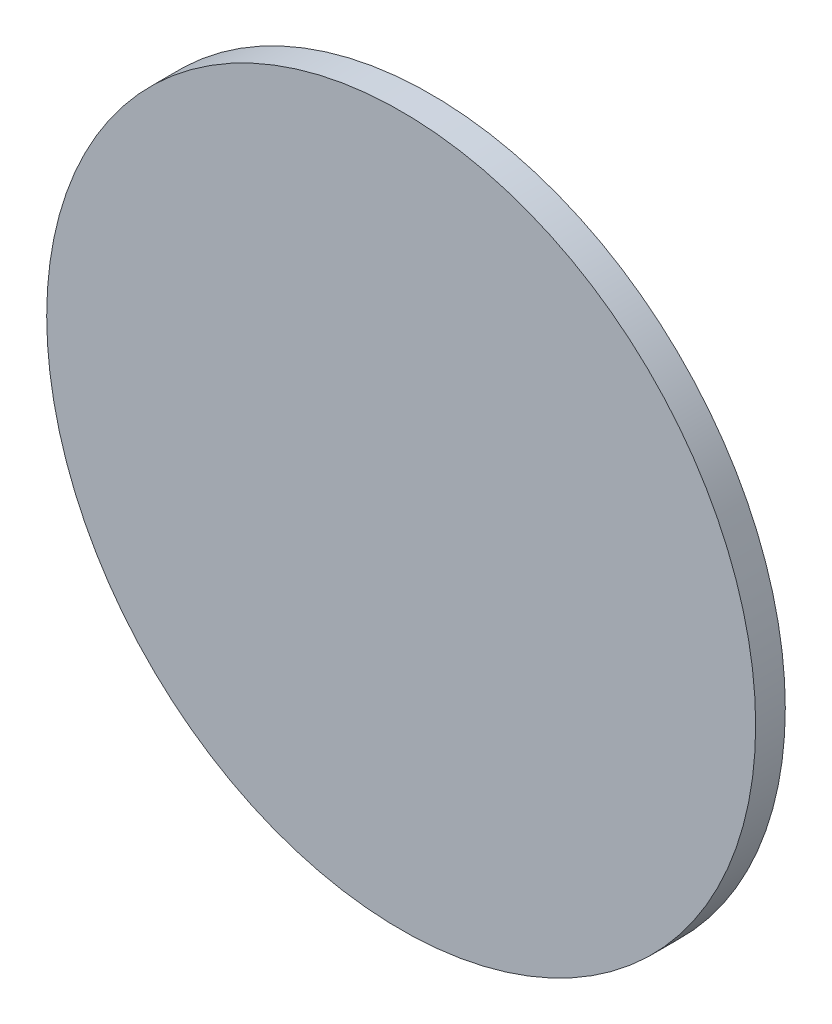
from build123d import *

# Parameters (mm, degrees)
SKETCH1_R           = 75.946
BOSS_EXTRUDE1_DEPTH = 6.35


with BuildPart() as part:
    # Sketch1 → Boss-Extrude1 (new body)
    with BuildSketch(Plane.XY):
        Circle(SKETCH1_R)
    extrude(amount=BOSS_EXTRUDE1_DEPTH)


solid = part.part
